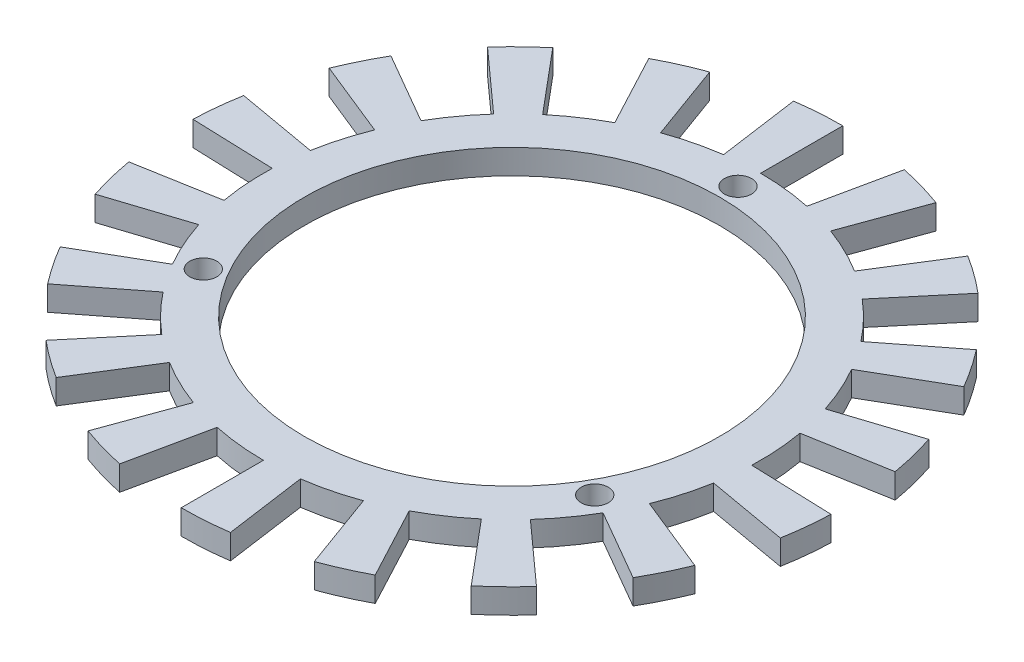
from build123d import *

# Parameters (mm, degrees)
SKETCH1_R           = 30.25
SKETCH1_R_2         = 25.25
EXTRUDE_THIN1_DEPTH = 3
SKETCH2_R           = 1.65
CUT_EXTRUDE3_DEPTH  = 10
BOSS_EXTRUDE1_DEPTH = 3


with BuildPart() as part:
    # Sketch1 → Extrude-Thin1 (new body)
    with BuildSketch(Plane(origin=(0, 0, 0), x_dir=(1, 0, 0), z_dir=(0, 1, 0))):
        Circle(SKETCH1_R)
        Circle(SKETCH1_R_2, mode=Mode.SUBTRACT)
    extrude(amount=-EXTRUDE_THIN1_DEPTH)

    # Sketch2 → Cut-Extrude3 (cut)
    with BuildSketch(Plane(origin=(0, 0, 0), x_dir=(1, 0, 0), z_dir=(0, 1, 0))):
        with Locations((0, 27.5)):
            Circle(SKETCH2_R)
        with Locations((23.815698604, -13.75)):
            Circle(SKETCH2_R)
        with Locations((-23.815698604, -13.75)):
            Circle(SKETCH2_R)
    extrude(amount=-CUT_EXTRUDE3_DEPTH, mode=Mode.SUBTRACT)

    # Sketch5 → Boss-Extrude1 (add)
    with BuildSketch(Plane.XZ.offset(3)):
        with BuildLine():
            Line((0, 40.25), (0, 30.25))
            ThreePointArc((0, 30.25), (2.110133331, 30.17631252), (4.209986304, 29.955609079))
            Line((4.209986304, 29.955609079), (5.601717314, 39.858289767))
            ThreePointArc((5.601717314, 39.858289767), (2.807698068, 40.151953023), (0, 40.25))
        make_face()
        with BuildLine():
            Line((13.766310769, 37.822627987), (10.346109336, 28.425701779))
            ThreePointArc((10.346109336, 28.425701779), (12.303783453, 27.634750094), (14.201514774, 26.709164684))
            Line((14.201514774, 26.709164684), (18.896230402, 35.538640613))
            ThreePointArc((18.896230402, 35.538640613), (16.371149884, 36.77020467), (13.766310769, 37.822627987))
        make_face()
        with BuildLine():
            Line((25.87220129, 30.833288836), (19.444325193, 23.172844404))
            ThreePointArc((19.444325193, 23.172844404), (21.013415706, 21.76002896), (22.480130971, 20.241200842))
            Line((22.480130971, 20.241200842), (29.911579225, 26.932506906))
            ThreePointArc((29.911579225, 26.932506906), (27.959999411, 28.953426964), (25.87220129, 30.833288836))
        make_face()
        with BuildLine():
            Line((34.857522502, 20.125), (26.197268464, 15.125))
            ThreePointArc((26.197268464, 15.125), (27.188519901, 13.26072719), (28.047311601, 11.331849451))
            Line((28.047311601, 11.331849451), (37.319150146, 15.077915385))
            ThreePointArc((37.319150146, 15.077915385), (36.176460364, 17.644438658), (34.857522502, 20.125))
        make_face()
        with BuildLine():
            Line((39.638512059, 6.989339151), (29.790434529, 5.252857374))
            ThreePointArc((29.790434529, 5.252857374), (30.084287335, 3.161986014), (30.231572517, 1.055709775))
            Line((30.231572517, 1.055709775), (40.225480788, 1.404704742))
            ThreePointArc((40.225480788, 1.404704742), (40.029506289, 4.207270647), (39.638512059, 6.989339151))
        make_face()
        with BuildLine():
            Line((39.638512059, -6.989339151), (29.790434529, -5.252857374))
            ThreePointArc((29.790434529, -5.252857374), (29.35144572, -7.318137342), (28.769459618, -9.34776408))
            Line((28.769459618, -9.34776408), (38.280024781, -12.437934024))
            ThreePointArc((38.280024781, -12.437934024), (39.054402983, -9.737356298), (39.638512059, -6.989339151))
        make_face()
        with BuildLine():
            Line((34.857522502, -20.125), (26.197268464, -15.125))
            ThreePointArc((26.197268464, -15.125), (25.07838657, -16.91558533), (23.837325297, -18.623759629))
            Line((23.837325297, -18.623759629), (31.717432833, -24.780374382))
            ThreePointArc((31.717432833, -24.780374382), (33.368762295, -22.507514365), (34.857522502, -20.125))
        make_face()
        with BuildLine():
            Line((25.87220129, -30.833288836), (19.444325193, -23.172844404))
            ThreePointArc((19.444325193, -23.172844404), (17.780503882, -24.47276408), (16.030057743, -25.653454909))
            Line((16.030057743, -25.653454909), (21.329250385, -34.13393587))
            ThreePointArc((21.329250385, -34.13393587), (23.658356405, -32.562934024), (25.87220129, -30.833288836))
        make_face()
        with BuildLine():
            Line((13.766310769, -37.822627987), (10.346109336, -28.425701779))
            ThreePointArc((10.346109336, -28.425701779), (8.338030013, -29.078166302), (6.289328647, -29.588964922))
            Line((6.289328647, -29.588964922), (8.368445555, -39.37044093))
            ThreePointArc((8.368445555, -39.37044093), (11.094403572, -38.690783262), (13.766310769, -37.822627987))
        make_face()
        with BuildLine():
            Line((0, -40.25), (0, -30.25))
            ThreePointArc((0, -30.25), (-2.110133331, -30.17631252), (-4.209986304, -29.955609079))
            Line((-4.209986304, -29.955609079), (-5.601717314, -39.858289767))
            ThreePointArc((-5.601717314, -39.858289767), (-2.807698068, -40.151953023), (0, -40.25))
        make_face()
        with BuildLine():
            Line((-13.766310769, -37.822627987), (-10.346109336, -28.425701779))
            ThreePointArc((-10.346109336, -28.425701779), (-12.303783453, -27.634750094), (-14.201514774, -26.709164684))
            Line((-14.201514774, -26.709164684), (-18.896230402, -35.538640613))
            ThreePointArc((-18.896230402, -35.538640613), (-16.371149884, -36.77020467), (-13.766310769, -37.822627987))
        make_face()
        with BuildLine():
            Line((-25.87220129, -30.833288836), (-19.444325193, -23.172844404))
            ThreePointArc((-19.444325193, -23.172844404), (-21.013415706, -21.76002896), (-22.480130971, -20.241200842))
            Line((-22.480130971, -20.241200842), (-29.911579225, -26.932506906))
            ThreePointArc((-29.911579225, -26.932506906), (-27.959999411, -28.953426964), (-25.87220129, -30.833288836))
        make_face()
        with BuildLine():
            Line((-34.857522502, -20.125), (-26.197268464, -15.125))
            ThreePointArc((-26.197268464, -15.125), (-27.188519901, -13.26072719), (-28.047311601, -11.331849451))
            Line((-28.047311601, -11.331849451), (-37.319150146, -15.077915385))
            ThreePointArc((-37.319150146, -15.077915385), (-36.176460364, -17.644438658), (-34.857522502, -20.125))
        make_face()
        with BuildLine():
            Line((-39.638512059, -6.989339151), (-29.790434529, -5.252857374))
            ThreePointArc((-29.790434529, -5.252857374), (-30.084287335, -3.161986014), (-30.231572517, -1.055709775))
            Line((-30.231572517, -1.055709775), (-40.225480788, -1.404704742))
            ThreePointArc((-40.225480788, -1.404704742), (-40.029506289, -4.207270647), (-39.638512059, -6.989339151))
        make_face()
        with BuildLine():
            Line((-39.638512059, 6.989339151), (-29.790434529, 5.252857374))
            ThreePointArc((-29.790434529, 5.252857374), (-29.35144572, 7.318137342), (-28.769459618, 9.34776408))
            Line((-28.769459618, 9.34776408), (-38.280024781, 12.437934024))
            ThreePointArc((-38.280024781, 12.437934024), (-39.054402983, 9.737356298), (-39.638512059, 6.989339151))
        make_face()
        with BuildLine():
            Line((-34.857522502, 20.125), (-26.197268464, 15.125))
            ThreePointArc((-26.197268464, 15.125), (-25.07838657, 16.91558533), (-23.837325297, 18.623759629))
            Line((-23.837325297, 18.623759629), (-31.717432833, 24.780374382))
            ThreePointArc((-31.717432833, 24.780374382), (-33.368762295, 22.507514365), (-34.857522502, 20.125))
        make_face()
        with BuildLine():
            Line((-25.87220129, 30.833288836), (-19.444325193, 23.172844404))
            ThreePointArc((-19.444325193, 23.172844404), (-17.780503882, 24.47276408), (-16.030057743, 25.653454909))
            Line((-16.030057743, 25.653454909), (-21.329250385, 34.13393587))
            ThreePointArc((-21.329250385, 34.13393587), (-23.658356405, 32.562934024), (-25.87220129, 30.833288836))
        make_face()
        with BuildLine():
            Line((-13.766310769, 37.822627987), (-10.346109336, 28.425701779))
            ThreePointArc((-10.346109336, 28.425701779), (-8.338030013, 29.078166302), (-6.289328647, 29.588964922))
            Line((-6.289328647, 29.588964922), (-8.368445555, 39.37044093))
            ThreePointArc((-8.368445555, 39.37044093), (-11.094403572, 38.690783262), (-13.766310769, 37.822627987))
        make_face()
    extrude(amount=-BOSS_EXTRUDE1_DEPTH)


solid = part.part
